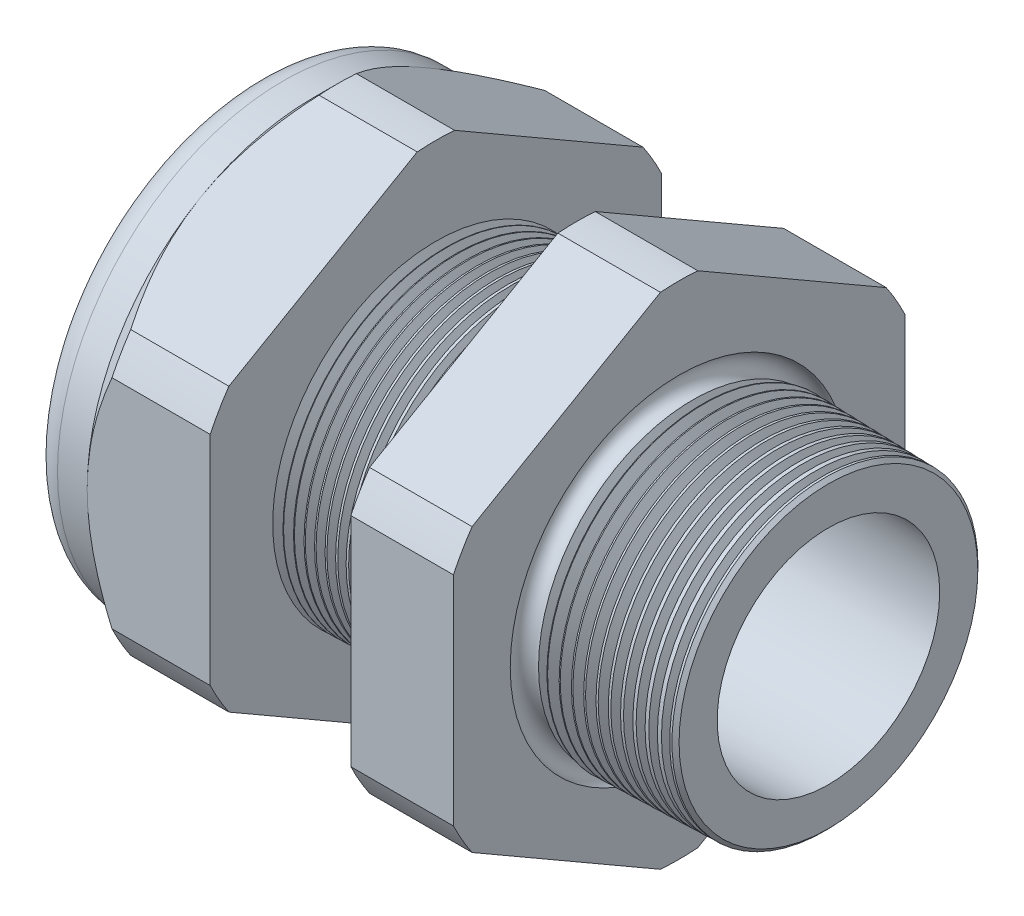
from build123d import *

# Parameters (mm, degrees)
SKETCH12_OUTSIDE_W = 88.514
SKETCH12_OUTSIDE_H = 88.514
CUT_EXTRUDE2_DEPTH = 38.71
FILLET4_R          = 2.032
SKETCH19_OUTSIDE_W = 55.962
SKETCH19_OUTSIDE_H = 59.594
SKETCH19_OUTSIDE_R = 16.51
CUT_EXTRUDE3_DEPTH = 3.99796
CUT_EXTRUDE3_DRAFT = -45
CHAMFER1_SIZE      = 0.260919487
CHAMFER1_SIZE2     = 0.254
SKETCH21_R         = 9.017
PLUG_DEPTH         = 8.89
SKETCH22_R         = 8.763
CUT_EXTRUDE4_DEPTH = 0.508
LPATTERN1_COUNT    = 14
LPATTERN1_PITCH    = 0.762
LPATTERN2_COUNT    = 12
LPATTERN2_PITCH    = 0.889
SKETCH32_R         = 0.889


with BuildPart() as part:
    # Sketch10 → Revolve2 (revolve)
    with BuildSketch(Plane.XY, mode=Mode.PRIVATE) as revolve2_sk:
        Polygon((-38.862, 9.017), (-25.662, 9.017), (3.048, 8.138202192), (3.048, 11.186202192), (-7.874, 11.472204827), (-7.874, 33.02), (-15.374, 33.02), (-15.374, 11.668599239), (-25.662, 11.938), (-25.662, 33.02), (-34.662, 33.02), (-34.662, 16.51), (-38.862, 16.51), align=None)
    revolve(revolve2_sk.sketch.rotate(Axis((0, 0, 0), (-1, 0, 0)), 90), axis=Axis((0, 0, 0), (-1, 0, 0)))  # turned: the seam where the file's is

    # Sketch12 outside → Cut-Extrude2 (cut, through all)
    with BuildSketch(Plane.ZY.offset(34.662)):
        Rectangle(SKETCH12_OUTSIDE_W, SKETCH12_OUTSIDE_H)
        with BuildLine():
            Line((-1.366648898, 18.27507078), (-15.143351102, 10.321088053))
            ThreePointArc((-15.143351102, 10.321088053), (-15.870868152, 9.16305), (-16.51, 7.953982726))
            Line((-16.51, 7.953982726), (-16.51, -7.953982726))
            ThreePointArc((-16.51, -7.953982726), (-15.870868152, -9.16305), (-15.143351102, -10.321088053))
            Line((-15.143351102, -10.321088053), (-1.366648898, -18.27507078))
            ThreePointArc((-1.366648898, -18.27507078), (0, -18.3261), (1.366648898, -18.27507078))
            Line((1.366648898, -18.27507078), (15.143351102, -10.321088053))
            ThreePointArc((15.143351102, -10.321088053), (15.870868152, -9.16305), (16.51, -7.953982726))
            Line((16.51, -7.953982726), (16.51, 7.953982726))
            ThreePointArc((16.51, 7.953982726), (15.870868152, 9.16305), (15.143351102, 10.321088053))
            Line((15.143351102, 10.321088053), (1.366648898, 18.27507078))
            ThreePointArc((1.366648898, 18.27507078), (0, 18.3261), (-1.366648898, 18.27507078))
        make_face(mode=Mode.SUBTRACT)
    extrude(amount=-CUT_EXTRUDE2_DEPTH, mode=Mode.SUBTRACT)

    # Fillet4
    fillet4_edges = [part.edges().sort_by_distance(p)[0] for p in [
        (-38.862, 0, 16.51),
    ]]
    fillet(fillet4_edges, radius=FILLET4_R)


with BuildPart() as cut_extrude3_tool:
    # Sketch19 outside → Cut-Extrude3 (with draft: the straight prism first)
    with BuildSketch(Plane.ZY.offset(34.662)):
        Rectangle(SKETCH19_OUTSIDE_W, SKETCH19_OUTSIDE_H)
        Circle(SKETCH19_OUTSIDE_R, mode=Mode.SUBTRACT)
    extrude(amount=-CUT_EXTRUDE3_DEPTH)
    # Cut-Extrude3: the draft: its side faces are tilted about the plane it starts from
    cut_extrude3_sides = [cut_extrude3_tool.faces().sort_by_distance(p)[0] for p in [
        (-32.66302, -29.797, 0),
        (-32.66302, 0, 27.981),
        (-32.66302, 29.797, 0),
        (-32.66302, 0, -27.981),
        (-32.66302, 0, -16.51),
    ]]
    draft(cut_extrude3_sides, Plane.ZY.offset(34.662), CUT_EXTRUDE3_DRAFT)


with BuildPart() as part_1:
    add(part.part)

    # Cut-Extrude3: cut by cut_extrude3_tool
    add(cut_extrude3_tool.part, mode=Mode.SUBTRACT)

    # Chamfer1
    chamfer1_edges = [part_1.edges().sort_by_distance(p)[0] for p in [
        (3.048, 0, 11.186202192),
    ]]
    chamfer1_side = [part_1.faces().sort_by_distance(p)[0] for p in [
        (3.048, 0, 8.454595769),
    ]]
    chamfer(chamfer1_edges, length=CHAMFER1_SIZE, length2=CHAMFER1_SIZE2, reference=chamfer1_side[0])

    # Sketch29 → Cut-Revolve1 (revolve, cut)
    with BuildSketch(Plane.XY, mode=Mode.PRIVATE) as cut_revolve1_sk:
        Polygon((-25.662, 11.938), (-24.929016419, 11.918806149), (-25.312130572, 11.293620673), align=None)
    cut_revolve1 = revolve(cut_revolve1_sk.sketch.rotate(Axis((0, 0, 0), (-1, 0, 0)), 90), axis=Axis((0, 0, 0), (-1, 0, 0)), mode=Mode.SUBTRACT)  # turned: the seam where the file's is

    # LPattern1: Cut-Revolve1 ×14
    with Locations(*[(i * LPATTERN1_PITCH, 0, 0) for i in range(1, LPATTERN1_COUNT)]):
        add(cut_revolve1, mode=Mode.SUBTRACT)

    # Sketch30 → Cut-Revolve2 (revolve, cut)
    with BuildSketch(Plane.XY, mode=Mode.PRIVATE) as cut_revolve2_sk:
        Polygon((-7.874, 11.472204827), (-6.994419703, 11.449172206), (-7.454156686, 10.698949635), align=None)
    cut_revolve2 = revolve(cut_revolve2_sk.sketch.rotate(Axis((0, 0, 0), (-1, 0, 0)), 270), axis=Axis((0, 0, 0), (-1, 0, 0)), mode=Mode.SUBTRACT)  # turned: the seam where the file's is

    # LPattern2: Cut-Revolve2 ×12
    with Locations(*[(i * LPATTERN2_PITCH, 0, 0) for i in range(1, LPATTERN2_COUNT)]):
        add(cut_revolve2, mode=Mode.SUBTRACT)

    # Sketch32 → Cut-Revolve3 (revolve, cut)
    with BuildSketch(Plane.XY, mode=Mode.PRIVATE) as cut_revolve3_sk:
        with Locations((-7.747, 11.472204827)):
            Circle(SKETCH32_R)
    revolve(cut_revolve3_sk.sketch.rotate(Axis((0, 0, 0), (-1, 0, 0)), 270), axis=Axis((0, 0, 0), (-1, 0, 0)), mode=Mode.SUBTRACT)  # turned: the seam where the file's is


with BuildPart() as body_2:
    # Sketch21 → plug (new body)
    with BuildSketch(Plane.ZY.offset(38.862)):
        Circle(SKETCH21_R)
    extrude(amount=-PLUG_DEPTH)

    # Sketch22 → Cut-Extrude4 (cut)
    with BuildSketch(Plane.ZY.offset(38.862)):
        Circle(SKETCH22_R)
    extrude(amount=-CUT_EXTRUDE4_DEPTH, mode=Mode.SUBTRACT)


solid = Compound([part_1.part, body_2.part])
